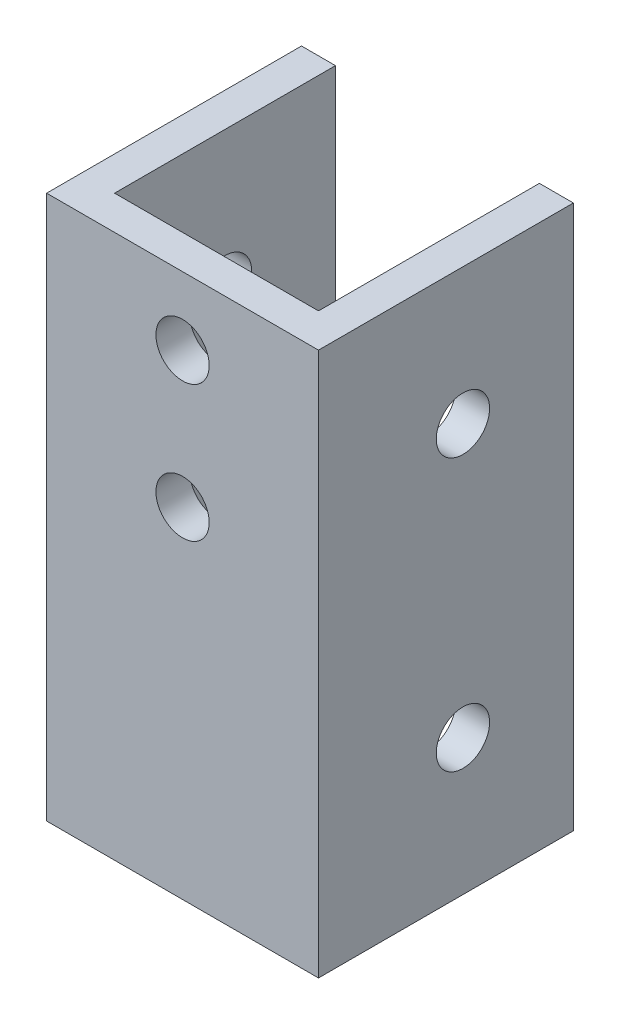
from build123d import *

# Parameters (mm, degrees)
BOSS_EXTRUDE1_DEPTH     = 50.8
SKETCH6_R               = 2.4892
CUT_EXTRUDE2_DEPTH      = 23.225
CUT_EXTRUDE2_DEPTH_BACK = 4.175
SKETCH5_R               = 2.4892
CUT_EXTRUDE1_DEPTH      = 24.8125


with BuildPart() as part:
    # Sketch1 → Boss-Extrude1 (new body)
    with BuildSketch(Plane(origin=(0, 0, 0), x_dir=(1, 0, 0), z_dir=(0, 1, 0))):
        Polygon((0, 0), (25.4, 0), (25.4, 23.8125), (22.225, 23.8125), (22.225, 3.175), (3.175, 3.175), (3.175, 23.8125), (0, 23.8125), align=None)
    extrude(amount=BOSS_EXTRUDE1_DEPTH)

    # Sketch6 → Cut-Extrude2 (cut, two sides)
    with BuildSketch(Plane(origin=(3.175, 0, 0), x_dir=(0, 0, -1), z_dir=(1, 0, 0))) as cut_extrude2_sk:
        with Locations((13.49375, 12.7)):
            Circle(SKETCH6_R)
        with Locations((13.49375, 38.1)):
            Circle(SKETCH6_R)
    extrude(amount=CUT_EXTRUDE2_DEPTH, mode=Mode.SUBTRACT)
    extrude(cut_extrude2_sk.sketch, amount=-CUT_EXTRUDE2_DEPTH_BACK, mode=Mode.SUBTRACT)

    # Sketch5 → Cut-Extrude1 (cut, through all)
    with BuildSketch(Plane.XY):
        with Locations((12.7, 44.45)):
            Circle(SKETCH5_R)
        with Locations((12.7, 31.75)):
            Circle(SKETCH5_R)
    extrude(amount=-CUT_EXTRUDE1_DEPTH, mode=Mode.SUBTRACT)


solid = part.part
